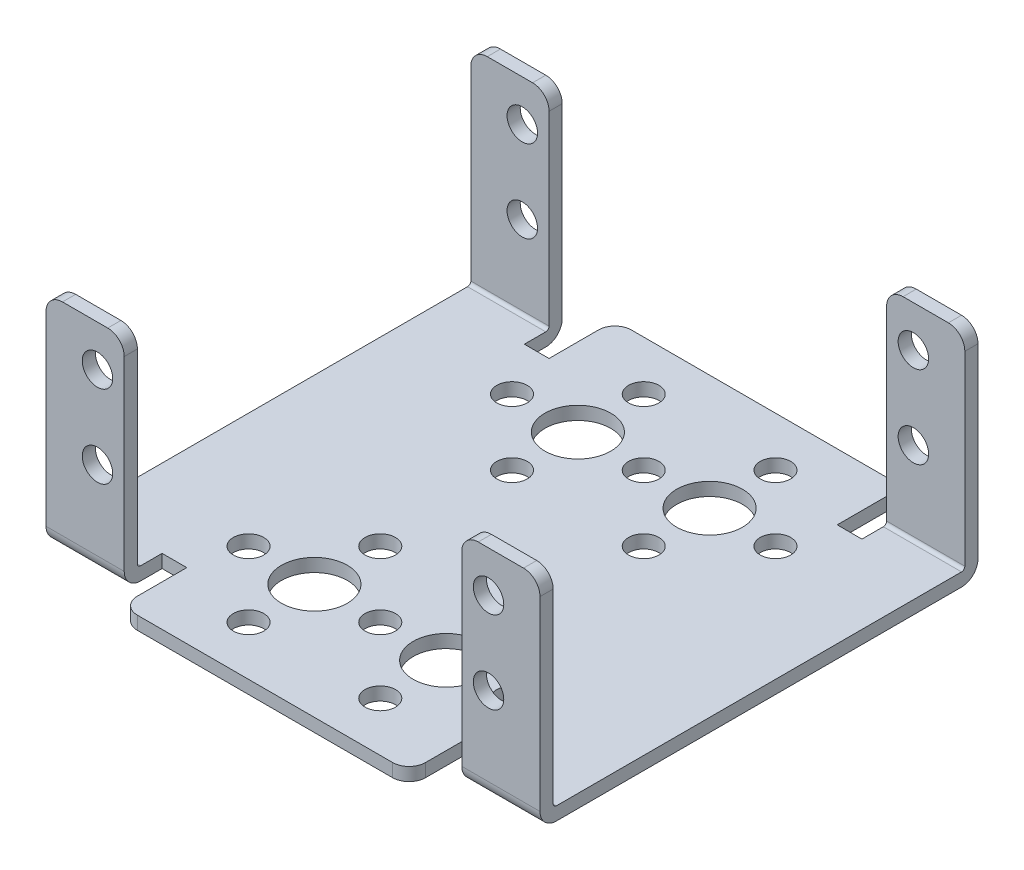
from build123d import *

# Parameters (mm, degrees)
SKETCH1_W                      = 53.2
SKETCH1_H                      = 26.6
BOSS_EXTRUDE1_DEPTH            = 9.5
SKETCH2_W                      = 50
SKETCH2_H                      = 25
CUT_EXTRUDE1_DEPTH             = 10.5
SKETCH3_W                      = 44
SKETCH3_H                      = 1.6
BOSS_EXTRUDE2_DEPTH            = 50.5
SKETCH4_W                      = 9.5
SKETCH4_H                      = 1.6
BOSS_EXTRUDE3_DEPTH            = 4.6
SKETCH5_W                      = 9.5
SKETCH5_H                      = 1.6
BOSS_EXTRUDE4_DEPTH            = 25
SKETCH6_W                      = 9.5
SKETCH6_H                      = 1.6
BOSS_EXTRUDE5_DEPTH            = 4.6
SKETCH7_W                      = 9.5
SKETCH7_H                      = 1.6
BOSS_EXTRUDE6_DEPTH            = 25
SKETCH8_W                      = 35
SKETCH8_H                      = 1.6
BOSS_EXTRUDE7_DEPTH            = 8
SKETCH9_W                      = 35
SKETCH9_H                      = 1.6
BOSS_EXTRUDE8_DEPTH            = 8
F_8_0_8_DIAMETER_HOLE1_D       = 8
F_8_0_8_DIAMETER_HOLE1_DEPTH   = 26.6
F_3_7_3_7_DIAMETER_HOLE1_D     = 3.7
F_3_7_3_7_DIAMETER_HOLE1_DEPTH = 26.6
F_3_7_3_7_DIAMETER_HOLE2_D     = 3.7
F_3_7_3_7_DIAMETER_HOLE2_DEPTH = 1.6
F_3_7_3_7_DIAMETER_HOLE3_D     = 3.7
F_3_7_3_7_DIAMETER_HOLE3_DEPTH = 56.6
FILLET1_R                      = 0.4
FILLET2_R                      = 2


with BuildPart() as part:
    # Sketch1 → Boss-Extrude1 (new body)
    with BuildSketch(Plane(origin=(60, 0, 0), x_dir=(0, 0, -1), z_dir=(1, 0, 0))):
        with Locations((26.6, 13.3)):
            Rectangle(SKETCH1_W, SKETCH1_H)
    extrude(amount=-BOSS_EXTRUDE1_DEPTH)

    # Sketch2 → Cut-Extrude1 (cut, through all)
    with BuildSketch(Plane.ZY.offset(-50.5)):
        with Locations((-26.6, 14.1)):
            Rectangle(SKETCH2_W, SKETCH2_H)
    extrude(amount=-CUT_EXTRUDE1_DEPTH, mode=Mode.SUBTRACT)

    # Sketch3 → Boss-Extrude2 (add)
    with BuildSketch(Plane.ZY.offset(-50.5)):
        with Locations((-26.6, 0.8)):
            Rectangle(SKETCH3_W, SKETCH3_H)
    extrude(amount=BOSS_EXTRUDE2_DEPTH)

    # Sketch4 → Boss-Extrude3 (add)
    with BuildSketch(Plane(origin=(0, 0, -48.6), x_dir=(-1, 0, 0), z_dir=(0, 0, -1))):
        with Locations((-4.75, 0.8)):
            Rectangle(SKETCH4_W, SKETCH4_H)
    extrude(amount=BOSS_EXTRUDE3_DEPTH)

    # Sketch5 → Boss-Extrude4 (add)
    with BuildSketch(Plane(origin=(0, 1.6, 0), x_dir=(-1, 0, 0), z_dir=(0, 1, 0))):
        with Locations((-4.75, -52.4)):
            Rectangle(SKETCH5_W, SKETCH5_H)
    extrude(amount=BOSS_EXTRUDE4_DEPTH)

    # Sketch6 → Boss-Extrude5 (add)
    with BuildSketch(Plane.XY.offset(-4.6)):
        with Locations((4.75, 0.8)):
            Rectangle(SKETCH6_W, SKETCH6_H)
    extrude(amount=BOSS_EXTRUDE5_DEPTH)

    # Sketch7 → Boss-Extrude6 (add)
    with BuildSketch(Plane(origin=(0, 1.6, 0), x_dir=(-1, 0, 0), z_dir=(0, 1, 0))):
        with Locations((-4.75, -0.8)):
            Rectangle(SKETCH7_W, SKETCH7_H)
    extrude(amount=BOSS_EXTRUDE6_DEPTH)

    # Sketch8 → Boss-Extrude7 (add)
    with BuildSketch(Plane(origin=(0, 0, -48.6), x_dir=(-1, 0, 0), z_dir=(0, 0, -1))):
        with Locations((-30, 0.8)):
            Rectangle(SKETCH8_W, SKETCH8_H)
    extrude(amount=BOSS_EXTRUDE7_DEPTH)

    # Sketch9 → Boss-Extrude8 (add)
    with BuildSketch(Plane.XY.offset(-4.6)):
        with Locations((30, 0.8)):
            Rectangle(SKETCH9_W, SKETCH9_H)
    extrude(amount=BOSS_EXTRUDE8_DEPTH)

    # Ø8.0 (8) Diameter Hole1
    with Locations(Plane(origin=(0, 0, 0), x_dir=(-1, 0, 0), z_dir=(0, -1, 0))):
        with Locations((-22, 42.6), (-22, 10.6), (-38, 42.6), (-38, 10.6)):
            Hole(F_8_0_8_DIAMETER_HOLE1_D / 2, depth=F_8_0_8_DIAMETER_HOLE1_DEPTH)

    # Ø3.7 (3.7) Diameter Hole1
    with Locations(Plane(origin=(0, 0, 0), x_dir=(-1, 0, 0), z_dir=(0, -1, 0))):
        with Locations((-30, 42.6), (-22, 18.6), (-14, 10.6), (-22, 2.6), (-22, 50.6), (-14, 42.6), (-22, 34.6), (-38, 18.6), (-46, 10.6), (-38, 2.6), (-38, 50.6), (-46, 42.6), (-38, 34.6), (-30, 10.6)):
            Hole(F_3_7_3_7_DIAMETER_HOLE1_D / 2, depth=F_3_7_3_7_DIAMETER_HOLE1_DEPTH)

    # Ø3.7 (3.7) Diameter Hole2
    with Locations(Plane(origin=(0, 0, -53.2), x_dir=(-1, 0, 0), z_dir=(0, 0, -1))):
        with Locations((-53.75, 11.6), (-53.75, 21.6), (-6.25, 11.6), (-6.25, 21.6)):
            Hole(F_3_7_3_7_DIAMETER_HOLE2_D / 2, depth=F_3_7_3_7_DIAMETER_HOLE2_DEPTH)

    # Ø3.7 (3.7) Diameter Hole3
    with Locations(Plane.XY):
        with Locations((53.75, 11.6), (53.75, 21.6), (6.25, 11.6), (6.25, 21.6)):
            Hole(F_3_7_3_7_DIAMETER_HOLE3_D / 2, depth=F_3_7_3_7_DIAMETER_HOLE3_DEPTH)

    # Fillet1
    fillet1_edges = [part.edges().sort_by_distance(p)[0] for p in [
        (4.75, 1.6, -51.6),
        (55.25, 1.6, -1.6),
        (4.75, 1.6, -1.6),
        (55.25, 1.6, -51.6),
    ]]
    fillet(fillet1_edges, radius=FILLET1_R)

    # Fillet2
    fillet2_edges = [part.edges().sort_by_distance(p)[0] for p in [
        (4.75, 0, 0),
        (4.75, 0, -53.2),
        (55.25, 0, -53.2),
        (47.5, 0.8, 3.4),
        (60, 26.6, -0.8),
        (12.5, 0.8, -56.6),
        (50.5, 26.6, -52.4),
        (12.5, 0.8, 3.4),
        (60, 26.6, -52.4),
        (55.25, 0, 0),
        (0, 26.6, -52.4),
        (47.5, 0.8, -56.6),
        (9.5, 26.6, -52.4),
        (9.5, 26.6, -0.8),
        (0, 26.6, -0.8),
        (50.5, 26.6, -0.8),
    ]]
    fillet(fillet2_edges, radius=FILLET2_R)


solid = part.part
